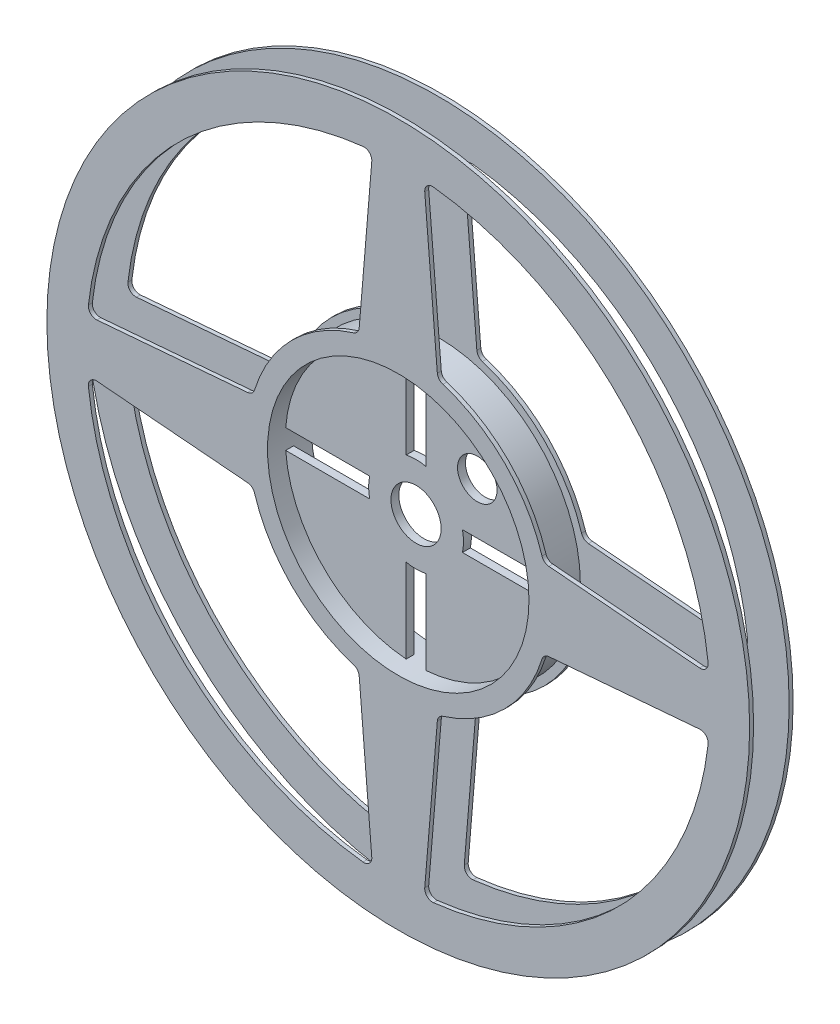
from build123d import *

# Parameters (mm, degrees)
SKETCH1_R           = 88.9
SKETCH1_R_2         = 33.075
BOSS_EXTRUDE1_DEPTH = 1
SKETCH2_R           = 36.075
SKETCH2_R_2         = 33.075
BOSS_EXTRUDE2_DEPTH = 3.5
SKETCH3_R           = 36.075
SKETCH3_R_2         = 33.075
SKETCH3_R_3         = 5
BOSS_EXTRUDE3_DEPTH = 1


with BuildPart() as part:
    # Sketch1 → Boss-Extrude1 (new body)
    with BuildSketch(Plane.XY):
        Circle(SKETCH1_R)
        Circle(SKETCH1_R_2, mode=Mode.SUBTRACT)
        with BuildLine():
            Line((-6.699774442, 76.240588003), (-9.885609858, 38.107539665))
            ThreePointArc((-9.885609858, 38.107539665), (-10.319263885, 37.02174666), (-11.285844597, 36.363929061))
            ThreePointArc((-11.285844597, 36.363929061), (-26.923090694, 26.923090694), (-36.363929061, 11.285844597))
            ThreePointArc((-36.363929061, 11.285844597), (-37.02174666, 10.319263885), (-38.107539665, 9.885609858))
            Line((-38.107539665, 9.885609858), (-76.240588003, 6.699774442))
            ThreePointArc((-76.240588003, 6.699774442), (-77.842317358, 7.299939499), (-78.39427914, 8.918912388))
            ThreePointArc((-78.39427914, 8.918912388), (-55.790725036, 55.790725036), (-8.918912388, 78.39427914))
            ThreePointArc((-8.918912388, 78.39427914), (-7.299939499, 77.842317358), (-6.699774442, 76.240588003))
        make_face(mode=Mode.SUBTRACT)
        with BuildLine():
            Line((6.699774442, 76.240588003), (9.885609858, 38.107539665))
            ThreePointArc((9.885609858, 38.107539665), (10.319263885, 37.02174666), (11.285844597, 36.363929061))
            ThreePointArc((11.285844597, 36.363929061), (26.923090694, 26.923090694), (36.363929061, 11.285844597))
            ThreePointArc((36.363929061, 11.285844597), (37.02174666, 10.319263885), (38.107539665, 9.885609858))
            Line((38.107539665, 9.885609858), (76.240588003, 6.699774442))
            ThreePointArc((76.240588003, 6.699774442), (77.842317358, 7.299939499), (78.39427914, 8.918912388))
            ThreePointArc((78.39427914, 8.918912388), (55.790725036, 55.790725036), (8.918912388, 78.39427914))
            ThreePointArc((8.918912388, 78.39427914), (7.299939499, 77.842317358), (6.699774442, 76.240588003))
        make_face(mode=Mode.SUBTRACT)
        with BuildLine():
            Line((76.240588003, -6.699774442), (38.107539665, -9.885609858))
            ThreePointArc((38.107539665, -9.885609858), (37.02174666, -10.319263885), (36.363929061, -11.285844597))
            ThreePointArc((36.363929061, -11.285844597), (26.923090694, -26.923090694), (11.285844597, -36.363929061))
            ThreePointArc((11.285844597, -36.363929061), (10.319263885, -37.02174666), (9.885609858, -38.107539665))
            Line((9.885609858, -38.107539665), (6.699774442, -76.240588003))
            ThreePointArc((6.699774442, -76.240588003), (7.299939499, -77.842317358), (8.918912388, -78.39427914))
            ThreePointArc((8.918912388, -78.39427914), (55.790725036, -55.790725036), (78.39427914, -8.918912388))
            ThreePointArc((78.39427914, -8.918912388), (77.842317358, -7.299939499), (76.240588003, -6.699774442))
        make_face(mode=Mode.SUBTRACT)
        with BuildLine():
            Line((-9.885609858, -38.107539665), (-6.699774442, -76.240588003))
            ThreePointArc((-6.699774442, -76.240588003), (-7.299939499, -77.842317358), (-8.918912388, -78.39427914))
            ThreePointArc((-8.918912388, -78.39427914), (-55.790725036, -55.790725036), (-78.39427914, -8.918912388))
            ThreePointArc((-78.39427914, -8.918912388), (-77.842317358, -7.299939499), (-76.240588003, -6.699774442))
            Line((-76.240588003, -6.699774442), (-38.107539665, -9.885609858))
            ThreePointArc((-38.107539665, -9.885609858), (-37.02174666, -10.319263885), (-36.363929061, -11.285844597))
            ThreePointArc((-36.363929061, -11.285844597), (-26.923090694, -26.923090694), (-11.285844597, -36.363929061))
            ThreePointArc((-11.285844597, -36.363929061), (-10.319263885, -37.02174666), (-9.885609858, -38.107539665))
        make_face(mode=Mode.SUBTRACT)
    extrude(amount=BOSS_EXTRUDE1_DEPTH)

    # Sketch2 → Boss-Extrude2 (add)
    with BuildSketch(Plane(origin=(0, 0, 0), x_dir=(-1, 0, 0), z_dir=(0, 0, -1))):
        with Locations(Location((0, 0, 0), (0, 0, 180))):
            Circle(SKETCH2_R)
        Circle(SKETCH2_R_2, mode=Mode.SUBTRACT)
    extrude(amount=BOSS_EXTRUDE2_DEPTH)

    # Sketch3 → Boss-Extrude3 (add)
    with BuildSketch(Plane(origin=(0, 0, -3.5), x_dir=(-1, 0, 0), z_dir=(0, 0, -1))):
        with Locations(Location((0, 0, 0), (0, 0, 180))):
            Circle(SKETCH3_R)
        with Locations(Location((0, 0, 0), (0, 0, 4.334881134))):
            Circle(SKETCH3_R_2, mode=Mode.SUBTRACT)
        with BuildLine():
            Line((-2.5, 11.736694594), (-2.5, 32.980382427))
            ThreePointArc((-2.5, 32.980382427), (-23.387556788, 23.387556788), (-32.980382427, 2.5))
            Line((-32.980382427, 2.5), (-11.736694594, 2.5))
            ThreePointArc((-11.736694594, 2.5), (-12, 0), (-11.736694594, -2.5))
            Line((-11.736694594, -2.5), (-32.980382427, -2.5))
            ThreePointArc((-32.980382427, -2.5), (-23.387556788, -23.387556788), (-2.5, -32.980382427))
            Line((-2.5, -32.980382427), (-2.5, -11.736694594))
            ThreePointArc((-2.5, -11.736694594), (0, -12), (2.5, -11.736694594))
            Line((2.5, -11.736694594), (2.5, -32.980382427))
            ThreePointArc((2.5, -32.980382427), (23.387556788, -23.387556788), (32.980382427, -2.5))
            Line((32.980382427, -2.5), (11.736694594, -2.5))
            ThreePointArc((11.736694594, -2.5), (12, 0), (11.736694594, 2.5))
            Line((11.736694594, 2.5), (32.980382427, 2.5))
            ThreePointArc((32.980382427, 2.5), (23.387556788, 23.387556788), (2.5, 32.980382427))
            Line((2.5, 32.980382427), (2.5, 11.736694594))
            ThreePointArc((2.5, 11.736694594), (0, 12), (-2.5, 11.736694594))
        make_face()
        with Locations((-15.496643432, 15.496643432)):
            Circle(SKETCH3_R_3, mode=Mode.SUBTRACT)
        with BuildLine():
            ThreePointArc((-5.837165408, -2.5), (-6.35, 0), (-5.837165408, 2.5))
            ThreePointArc((-5.837165408, 2.5), (-4.490128061, 4.490128061), (-2.5, 5.837165408))
            ThreePointArc((-2.5, 5.837165408), (0, 6.35), (2.5, 5.837165408))
            ThreePointArc((2.5, 5.837165408), (4.490128061, 4.490128061), (5.837165408, 2.5))
            ThreePointArc((5.837165408, 2.5), (6.220470253, 1.27602893), (6.35, 0))
            ThreePointArc((6.35, 0), (6.220470253, -1.27602893), (5.837165408, -2.5))
            ThreePointArc((5.837165408, -2.5), (4.490128061, -4.490128061), (2.5, -5.837165408))
            ThreePointArc((2.5, -5.837165408), (0, -6.35), (-2.5, -5.837165408))
            ThreePointArc((-2.5, -5.837165408), (-4.490128061, -4.490128061), (-5.837165408, -2.5))
        make_face(mode=Mode.SUBTRACT)
    extrude(amount=BOSS_EXTRUDE3_DEPTH)

    # Mirror4: part across plane


with BuildPart() as part_1:
    add(part.part)
    add(part.part.mirror(Plane(origin=(-79.506421356, 0, -4.5), x_dir=(1, 0, 0), z_dir=(0, 0, -1))))


solid = part_1.part
